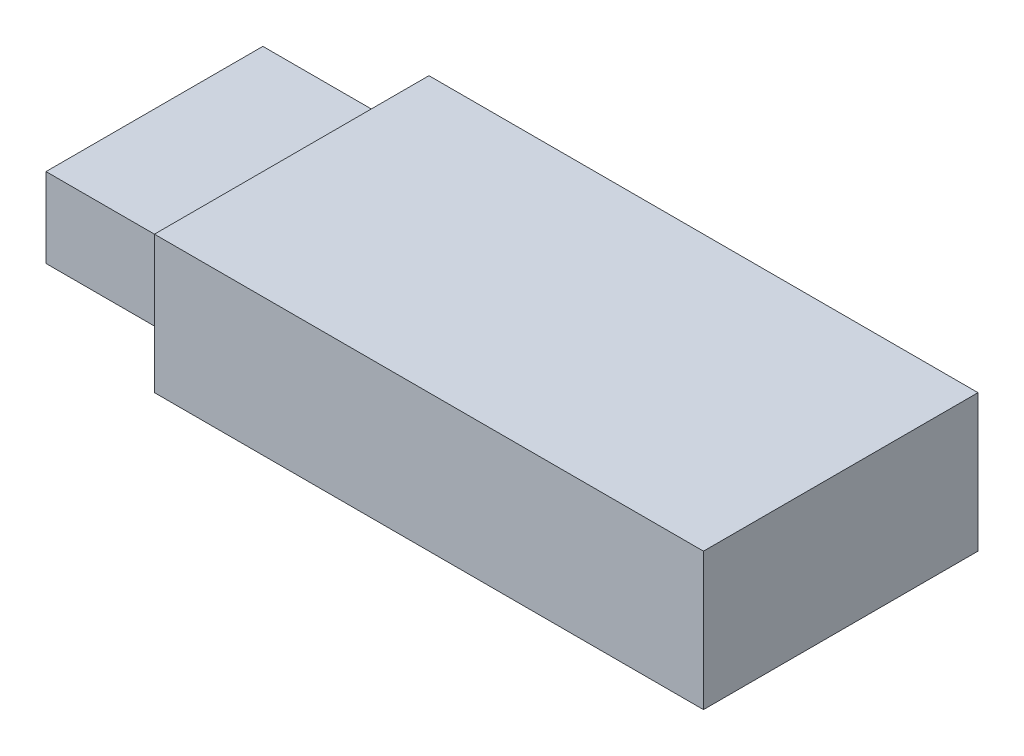
from build123d import *

# Parameters (mm, degrees)
SKETCH_1_W          = 100
SKETCH_1_H          = 40
EXTRUDE_1_DEPTH     = 20
SKETCH_3_W          = 40
SKETCH_3_H          = 20
SKETCH_3_W_2        = 32
SKETCH_3_H_2        = 12
CUT_EXTRUDE_4_DEPTH = 20
SKETCH_6_W          = 32
SKETCH_6_H          = 12
SKETCH_6_W_2        = 31.6
SKETCH_6_H_2        = 11.6
CUT_EXTRUDE_5_DEPTH = 20


with BuildPart() as part:
    # 草图1 → 凸台-拉伸1 (new body)
    with BuildSketch(Plane(origin=(0, 0, 0), x_dir=(1, 0, 0), z_dir=(0, 1, 0))):
        with Locations((50, 20)):
            Rectangle(SKETCH_1_W, SKETCH_1_H)
    extrude(amount=EXTRUDE_1_DEPTH)

    # 草图3 → 切除-拉伸4 (cut)
    with BuildSketch(Plane.ZY):
        with Locations((-20, 10)):
            Rectangle(SKETCH_3_W, SKETCH_3_H)
        with Locations((-20, 10)):
            Rectangle(SKETCH_3_W_2, SKETCH_3_H_2, mode=Mode.SUBTRACT)
    extrude(amount=-CUT_EXTRUDE_4_DEPTH, mode=Mode.SUBTRACT)

    # 草图6 → 切除-拉伸5 (cut)
    with BuildSketch(Plane.ZY):
        with Locations((-20, 10)):
            Rectangle(SKETCH_6_W, SKETCH_6_H)
        with Locations((-20, 10)):
            Rectangle(SKETCH_6_W_2, SKETCH_6_H_2, mode=Mode.SUBTRACT)
    extrude(amount=-CUT_EXTRUDE_5_DEPTH, mode=Mode.SUBTRACT)


solid = part.part
